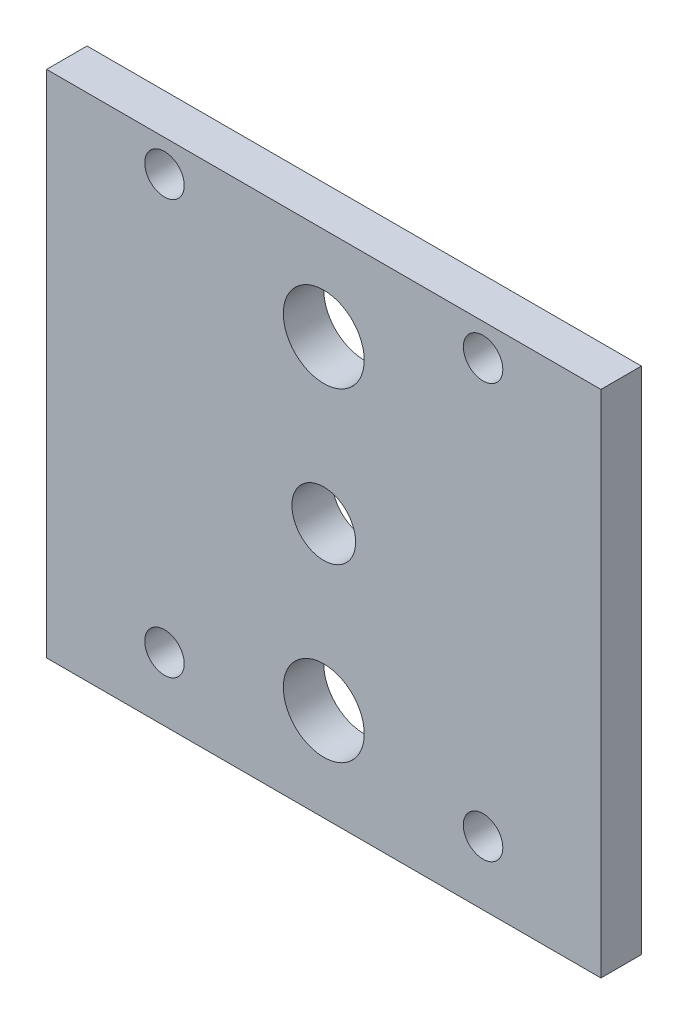
from build123d import *

# Parameters (mm, degrees)
CROQUIS1_W              = 87
CROQUIS1_H              = 80
CROQUIS1_R              = 3.1
CROQUIS1_R_2            = 6.35
CROQUIS1_R_3            = 5
SALIENTE_EXTRUIR1_DEPTH = 6.35


with BuildPart() as part:
    # Croquis1 → Saliente-Extruir1 (new body)
    with BuildSketch(Plane.XY):
        Rectangle(CROQUIS1_W, CROQUIS1_H)
        with Locations((-25, 35)):
            Circle(CROQUIS1_R, mode=Mode.SUBTRACT)
        with Locations((25, 35)):
            Circle(CROQUIS1_R, mode=Mode.SUBTRACT)
        with Locations((0, 25.4)):
            Circle(CROQUIS1_R_2, mode=Mode.SUBTRACT)
        with Locations((0, -25.4)):
            Circle(CROQUIS1_R_2, mode=Mode.SUBTRACT)
        with Locations((-25, -30)):
            Circle(CROQUIS1_R, mode=Mode.SUBTRACT)
        with Locations((25, -30)):
            Circle(CROQUIS1_R, mode=Mode.SUBTRACT)
        Circle(CROQUIS1_R_3, mode=Mode.SUBTRACT)
    extrude(amount=SALIENTE_EXTRUIR1_DEPTH)


solid = part.part
